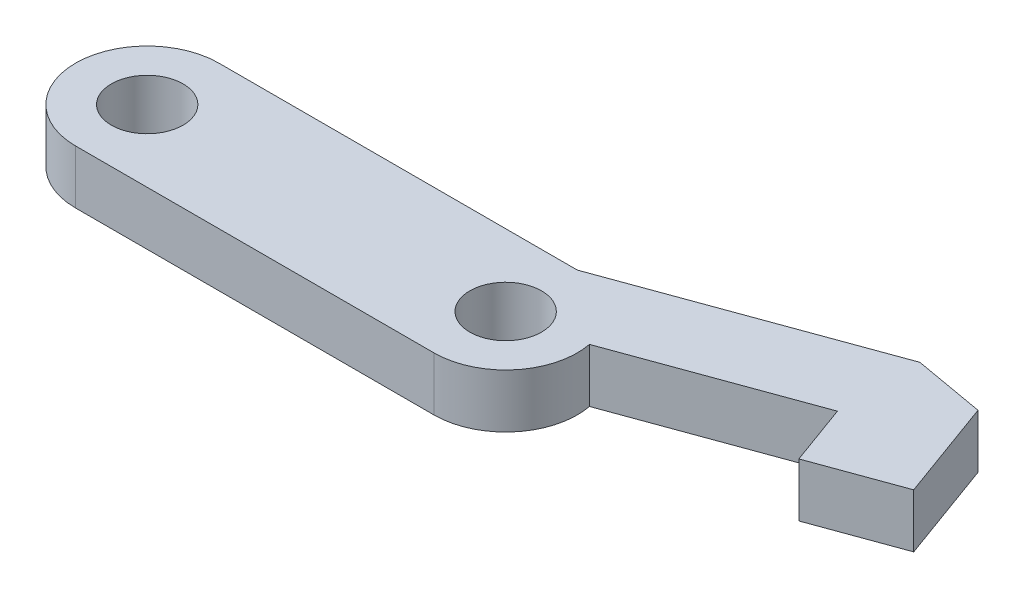
from build123d import *

# Parameters (mm, degrees)
BOSS_EXTRUDE1_DEPTH = 15
F_20_0MM_1_D        = 20
SCALE_1_SCALE       = 0.3


with BuildPart() as part:
    # Sketch1 → Boss-Extrude1 (new body)
    with BuildSketch(Plane(origin=(0, 0, 0), x_dir=(1, 0, 0), z_dir=(0, 1, 0))):
        with BuildLine():
            Line((0, 20), (-100, 20))
            ThreePointArc((-100, 20), (-120, 0), (-100, -20))
            Line((-100, -20), (0, -20))
            ThreePointArc((0, -20), (20, 0), (0, 20))
        make_face()
        with BuildLine():
            ThreePointArc((0, 20), (12.75180627, 15.407512352), (19.64736126, 3.739143686))
            Line((19.64736126, 3.739143686), (70.3513219, 22.193876119))
            Line((70.3513219, 22.193876119), (76.50768448, 5.279408944))
            Line((76.50768448, 5.279408944), (100, 13.829912528))
            Line((100, 13.829912528), (89.7393957, 42.020691151))
            Line((89.7393957, 42.020691151), (70.04324064, 45.493654704))
            Line((70.04324064, 45.493654704), (0, 20))
        make_face()
    extrude(amount=BOSS_EXTRUDE1_DEPTH)

    # Ø20.0mm 맞춤핀 구멍1 (through all)
    with Locations(Plane(origin=(0, 15, 0), x_dir=(1, 0, 0), z_dir=(0, 1, 0))):
        with Locations((-100, 0), (0, 0)):
            Hole(F_20_0MM_1_D / 2)


with BuildPart() as part_1:
    # 축척1: scaled about (-15.835607979, 7.5, -7.836280523)
    add(part.part.scale(SCALE_1_SCALE).moved(Location((-11.084925585, 5.25, -5.485396366))))


solid = part_1.part
